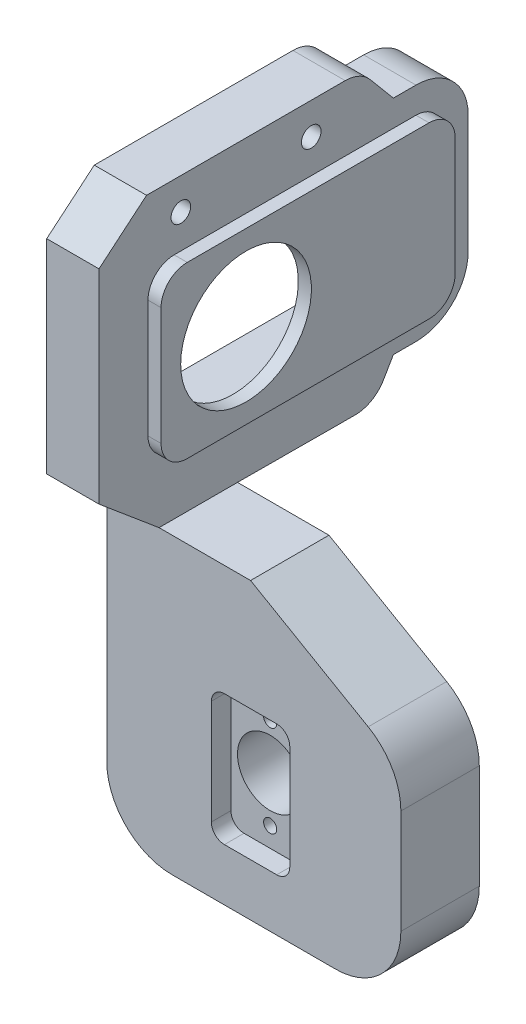
from build123d import *

# Parameters (mm, degrees)
BOSS_EXTRUDE1_DEPTH     = 12
CUT_EXTRUDE1_DEPTH      = 3
SKETCH1_4_R             = 5
SKETCH1_4_R_2           = 1
CUT_EXTRUDE2_DEPTH      = 65.761099435
BOSS_EXTRUDE2_DEPTH     = 8
BOSS_EXTRUDE3_DEPTH     = 10
CUT_EXTRUDE5_DEPTH      = 8
SKETCH3_7_R             = 10
CUT_EXTRUDE6_DEPTH      = 112.189012065
SKETCH7_R               = 1.280379455
CUT_EXTRUDE7_DEPTH      = 3
CUT_EXTRUDE8_DEPTH      = 109.198874319
CUT_EXTRUDE8_DEPTH_BACK = 109.198874319
SKETCH9_R               = 1.5


with BuildPart() as part:
    # Sketch1 → Boss-Extrude1 (new body)
    with BuildSketch(Plane.XY):
        with BuildLine():
            Line((0, 45), (0, 10))
            ThreePointArc((0, 10), (2.928932188, 2.928932188), (10, 0))
            Line((10, 0), (35, 0))
            ThreePointArc((35, 0), (42.071067812, 2.928932188), (45, 10))
            Line((45, 10), (45, 25.947441117))
            ThreePointArc((45, 25.947441117), (43.660254038, 30.947441117), (40, 34.607695155))
            Line((40, 34.607695155), (22, 45))
            Line((22, 45), (0, 45))
        make_face()
    extrude(amount=-BOSS_EXTRUDE1_DEPTH)

    # Sketch1_3 → Cut-Extrude1 (cut)
    with BuildSketch(Plane.XY):
        with BuildLine():
            ThreePointArc((16, 10), (16.585786438, 8.585786438), (18, 8))
            Line((18, 8), (26, 8))
            ThreePointArc((26, 8), (27.414213562, 8.585786438), (28, 10))
            Line((28, 10), (28, 26))
            ThreePointArc((28, 26), (27.414213562, 27.414213562), (26, 28))
            Line((26, 28), (18, 28))
            ThreePointArc((18, 28), (16.585786438, 27.414213562), (16, 26))
            Line((16, 26), (16, 10))
        make_face()
    extrude(amount=-CUT_EXTRUDE1_DEPTH, mode=Mode.SUBTRACT)

    # Sketch1_4 → Cut-Extrude2 (cut, through all)
    with BuildSketch(Plane.XY):
        with Locations((22, 18)):
            Circle(SKETCH1_4_R)
        with Locations((22, 11)):
            Circle(SKETCH1_4_R_2)
        with Locations((22, 25)):
            Circle(SKETCH1_4_R_2)
    extrude(amount=-CUT_EXTRUDE2_DEPTH, mode=Mode.SUBTRACT)

    # Sketch3 → Boss-Extrude2 (add)
    with BuildSketch(Plane.ZY):
        with BuildLine():
            Line((0, 45), (9.192533317, 52.713451316))
            Line((9.192533317, 52.713451316), (9.192533317, 83.893517708))
            Line((9.192533317, 83.893517708), (1.915111108, 90))
            Line((1.915111108, 90), (-28.48263132, 90))
            ThreePointArc((-28.48263132, 90), (-30.595722628, 89.531538935), (-32.312853535, 88.213938048))
            Line((-32.312853535, 88.213938048), (-35.850897987, 83.997460862))
            Line((-35.850897987, 83.997460862), (-39.307466683, 83.997460862))
            ThreePointArc((-39.307466683, 83.997460862), (-44.964320932, 81.654315111), (-47.307466683, 75.997460862))
            Line((-47.307466683, 75.997460862), (-47.307466683, 58))
            ThreePointArc((-47.307466683, 58), (-44.964320932, 52.343145751), (-39.307466683, 50))
            Line((-39.307466683, 50), (-35.850897987, 50))
            Line((-35.850897987, 50), (-34.340222638, 47.408116517))
            ThreePointArc((-34.340222638, 47.408116517), (-32.502582275, 45.585533814), (-29.999847687, 44.925951074))
            Line((-29.999847687, 44.925951074), (-12, 45))
            Line((-12, 45), (0, 45))
        make_face()
        with BuildLine():
            ThreePointArc((-0.307466683, 58), (-0.89325312, 56.585786438), (-2.307466683, 56))
            Line((-2.307466683, 56), (-39.307466683, 56))
            ThreePointArc((-39.307466683, 56), (-40.721680245, 56.585786438), (-41.307466683, 58))
            Line((-41.307466683, 58), (-41.307466683, 76))
            ThreePointArc((-41.307466683, 76), (-40.721680245, 77.414213562), (-39.307466683, 78))
            Line((-39.307466683, 78), (-2.307466683, 78))
            ThreePointArc((-2.307466683, 78), (-0.89325312, 77.414213562), (-0.307466683, 76))
            Line((-0.307466683, 76), (-0.307466683, 58))
        make_face(mode=Mode.SUBTRACT)
    extrude(amount=-BOSS_EXTRUDE2_DEPTH)

    # Sketch3_4 → Boss-Extrude3 (add)
    with BuildSketch(Plane.ZY):
        with BuildLine():
            ThreePointArc((-39.307466683, 79.997460862), (-42.135893807, 78.825887987), (-43.307466683, 75.997460862))
            Line((-43.307466683, 75.997460862), (-43.307466683, 58))
            ThreePointArc((-43.307466683, 58), (-42.135893807, 55.171572875), (-39.307466683, 54))
            Line((-39.307466683, 54), (-2.307466683, 54))
            ThreePointArc((-2.307466683, 54), (0.520960442, 55.171572875), (1.692533317, 58))
            Line((1.692533317, 58), (1.692533317, 75.997460862))
            ThreePointArc((1.692533317, 75.997460862), (0.520960442, 78.825887987), (-2.307466683, 79.997460862))
            Line((-2.307466683, 79.997460862), (-39.307466683, 79.997460862))
        make_face()
    extrude(amount=-BOSS_EXTRUDE3_DEPTH)

    # Sketch3_6 → Cut-Extrude5 (cut)
    with BuildSketch(Plane.ZY):
        with BuildLine():
            ThreePointArc((-39.307466683, 78), (-40.721680245, 77.414213562), (-41.307466683, 76))
            Line((-41.307466683, 76), (-41.307466683, 58))
            ThreePointArc((-41.307466683, 58), (-40.721680245, 56.585786438), (-39.307466683, 56))
            Line((-39.307466683, 56), (-2.307466683, 56))
            ThreePointArc((-2.307466683, 56), (-0.89325312, 56.585786438), (-0.307466683, 58))
            Line((-0.307466683, 58), (-0.307466683, 76))
            ThreePointArc((-0.307466683, 76), (-0.89325312, 77.414213562), (-2.307466683, 78))
            Line((-2.307466683, 78), (-39.307466683, 78))
        make_face()
    extrude(amount=-CUT_EXTRUDE5_DEPTH, mode=Mode.SUBTRACT)

    # Sketch3_7 → Cut-Extrude6 (cut, through all)
    with BuildSketch(Plane.ZY):
        with Locations((-11.307466683, 67)):
            Circle(SKETCH3_7_R)
    extrude(amount=-CUT_EXTRUDE6_DEPTH, mode=Mode.SUBTRACT)

    # Sketch7 → Cut-Extrude7 (cut)
    with BuildSketch(Plane.ZY):
        with Locations((-44.307466683, 72)):
            Circle(SKETCH7_R)
        with Locations((-44.307466683, 62)):
            Circle(SKETCH7_R)
        with Locations((2.692533317, 62)):
            Circle(SKETCH7_R)
        with Locations((2.692533317, 72)):
            Circle(SKETCH7_R)
    extrude(amount=-CUT_EXTRUDE7_DEPTH, mode=Mode.SUBTRACT)

    # Sketch9 → Cut-Extrude8 (cut, two sides: drawn at the far end of the back side and taken through both)
    with BuildSketch(Plane(origin=(8, 0, 0), x_dir=(0, 0, -1), z_dir=(1, 0, 0)).offset(-CUT_EXTRUDE8_DEPTH_BACK)):
        with Locations((3.333760106, 85.147460862)):
            Circle(SKETCH9_R)
        with Locations((23.283760106, 85.147460862)):
            Circle(SKETCH9_R)
    extrude(amount=CUT_EXTRUDE8_DEPTH + CUT_EXTRUDE8_DEPTH_BACK, mode=Mode.SUBTRACT)


solid = part.part
